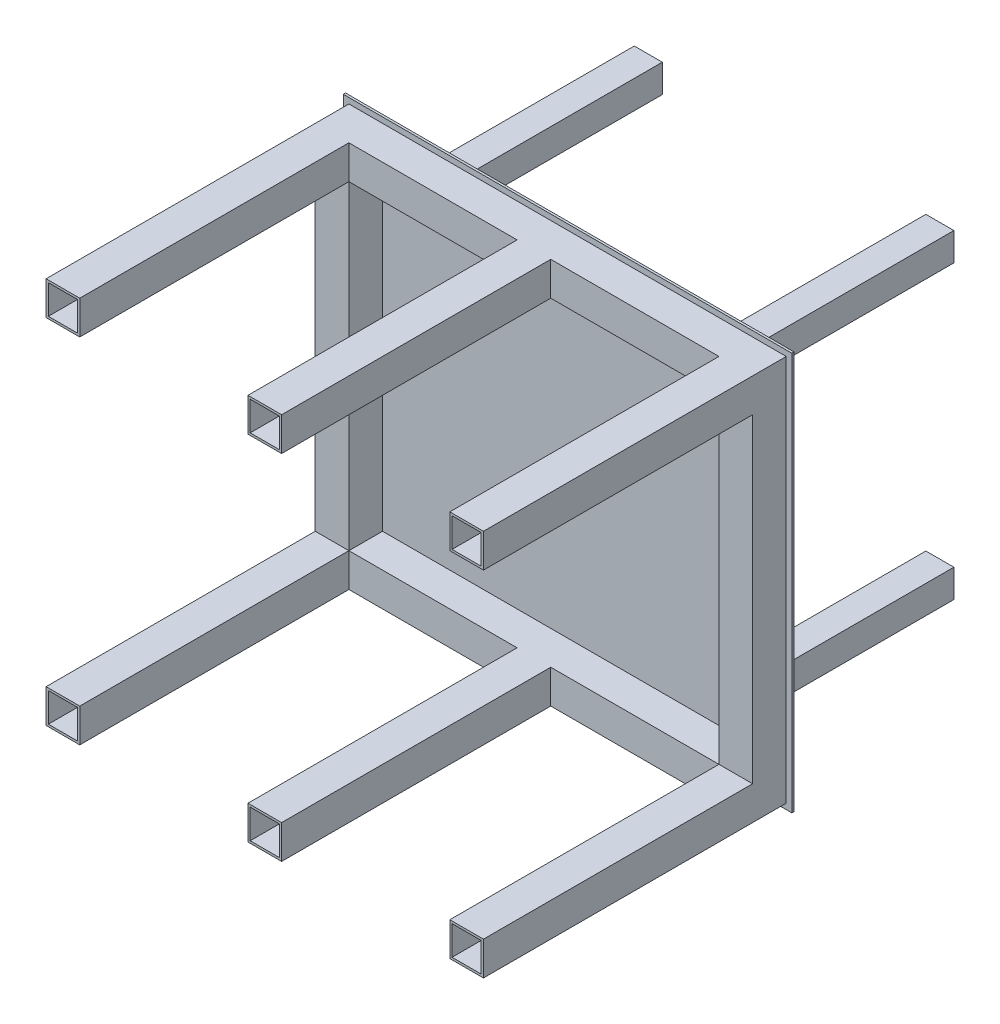
from build123d import *

# Parameters (mm, degrees)
SKETCH_1_W        = 30
SKETCH_1_H        = 30
SKETCH_1_W_2      = 26
SKETCH_1_H_2      = 26
EXTRUDE_1_DEPTH   = 270
EXTRUDE_1_2_DEPTH = 270
EXTRUDE_1_3_DEPTH = 270
EXTRUDE_1_4_DEPTH = 270
EXTRUDE_1_5_DEPTH = 270
EXTRUDE_1_6_DEPTH = 270
SKETCH_1_4_W      = 400
SKETCH_1_4_H      = 355
EXTRUDE_2_DEPTH   = 2
SKETCH_3_W        = 25
SKETCH_3_H        = 25
SKETCH_3_W_2      = 22
SKETCH_3_H_2      = 22
EXTRUDE_3_DEPTH   = 200
SKETCH_9_W        = 30
SKETCH_9_H        = 30
EXTRUDE_4_DEPTH   = 290
SKETCH_10_W       = 30
SKETCH_10_H       = 30
EXTRUDE_5_DEPTH   = 330


with BuildPart() as part:
    # 草圖1 → 填料-伸長1 (new body)
    with BuildSketch(Plane.XY):
        with Locations((-139.865693992, 17.660065035)):
            Rectangle(SKETCH_1_W, SKETCH_1_H)
        with Locations((-139.865693992, 17.660065035)):
            Rectangle(SKETCH_1_W_2, SKETCH_1_H_2, mode=Mode.SUBTRACT)
    extrude(amount=EXTRUDE_1_DEPTH)



with BuildPart() as body_2:
    # 草圖1 → Extrude 1 2 (new body)
    with BuildSketch(Plane.XY):
        with Locations((40.134306008, 17.660065035)):
            Rectangle(SKETCH_1_W, SKETCH_1_H)
        with Locations((40.134306008, 17.660065035)):
            Rectangle(SKETCH_1_W_2, SKETCH_1_H_2, mode=Mode.SUBTRACT)
    extrude(amount=EXTRUDE_1_2_DEPTH)


with BuildPart() as body_3:
    # 草圖1 → Extrude 1 3 (new body)
    with BuildSketch(Plane.XY):
        with Locations((220.134306008, 17.660065035)):
            Rectangle(SKETCH_1_W, SKETCH_1_H)
        with Locations((220.134306008, 17.660065035)):
            Rectangle(SKETCH_1_W_2, SKETCH_1_H_2, mode=Mode.SUBTRACT)
    extrude(amount=EXTRUDE_1_3_DEPTH)


with BuildPart() as body_4:
    # 草圖1 → Extrude 1 4 (new body)
    with BuildSketch(Plane.XY):
        with Locations((-139.865693992, -297.339934965)):
            Rectangle(SKETCH_1_W, SKETCH_1_H)
        with Locations((-139.865693992, -297.339934965)):
            Rectangle(SKETCH_1_W_2, SKETCH_1_H_2, mode=Mode.SUBTRACT)
    extrude(amount=EXTRUDE_1_4_DEPTH)


with BuildPart() as body_5:
    # 草圖1 → Extrude 1 5 (new body)
    with BuildSketch(Plane.XY):
        with Locations((40.134306008, -297.339934965)):
            Rectangle(SKETCH_1_W, SKETCH_1_H)
        with Locations((40.134306008, -297.339934965)):
            Rectangle(SKETCH_1_W_2, SKETCH_1_H_2, mode=Mode.SUBTRACT)
    extrude(amount=EXTRUDE_1_5_DEPTH)


with BuildPart() as body_6:
    # 草圖1 → Extrude 1 6 (new body)
    with BuildSketch(Plane.XY):
        with Locations((220.134306008, -297.339934965)):
            Rectangle(SKETCH_1_W, SKETCH_1_H)
        with Locations((220.134306008, -297.339934965)):
            Rectangle(SKETCH_1_W_2, SKETCH_1_H_2, mode=Mode.SUBTRACT)
    extrude(amount=EXTRUDE_1_6_DEPTH)


with BuildPart() as part_1:
    add(part.part)

    add(body_2.part)  # 填料-伸長2 merges body 2

    add(body_3.part)  # 填料-伸長2 merges body 3

    add(body_4.part)  # 填料-伸長2 merges body 4

    add(body_5.part)  # 填料-伸長2 merges body 5

    add(body_6.part)  # 填料-伸長2 merges body 6
    # 草圖1<4> → 填料-伸長2 (add)
    with BuildSketch(Plane.XY):
        with Locations((40.134306008, -139.839934965)):
            Rectangle(SKETCH_1_4_W, SKETCH_1_4_H)
    extrude(amount=-EXTRUDE_2_DEPTH)

    # 草圖3 → 填料-伸長3 (add)
    # profile 1 of 4: a face of its own
    with BuildSketch(Plane(origin=(0, 0, -2), x_dir=(-1, 0, 0), z_dir=(0, 0, -1))):
        with Locations((-170.134306008, -9.839934965)):
            Rectangle(SKETCH_3_W, SKETCH_3_H)
        with Locations((-170.134306008, -9.839934965)):
            Rectangle(SKETCH_3_W_2, SKETCH_3_H_2, mode=Mode.SUBTRACT)
    # profile 2 of 4: a face of its own
    with BuildSketch(Plane(origin=(0, 0, -2), x_dir=(-1, 0, 0), z_dir=(0, 0, -1))):
        with Locations((-170.134306008, -269.839934965)):
            Rectangle(SKETCH_3_W, SKETCH_3_H)
        with Locations((-170.134306008, -269.839934965)):
            Rectangle(SKETCH_3_W_2, SKETCH_3_H_2, mode=Mode.SUBTRACT)
    # profile 3 of 4: a face of its own
    with BuildSketch(Plane(origin=(0, 0, -2), x_dir=(-1, 0, 0), z_dir=(0, 0, -1))):
        with Locations((89.865693992, -269.839934965)):
            Rectangle(SKETCH_3_W, SKETCH_3_H)
        with Locations((89.865693992, -269.839934965)):
            Rectangle(SKETCH_3_W_2, SKETCH_3_H_2, mode=Mode.SUBTRACT)
    # profile 4 of 4: a face of its own
    with BuildSketch(Plane(origin=(0, 0, -2), x_dir=(-1, 0, 0), z_dir=(0, 0, -1))):
        with Locations((89.865693992, -9.839934965)):
            Rectangle(SKETCH_3_W, SKETCH_3_H)
        with Locations((89.865693992, -9.839934965)):
            Rectangle(SKETCH_3_W_2, SKETCH_3_H_2, mode=Mode.SUBTRACT)
    extrude(amount=EXTRUDE_3_DEPTH)

    # 草圖9 → 填料-伸長4 (add)
    with BuildSketch(Plane(origin=(0, -282.339934965, 0), x_dir=(1, 0, 0), z_dir=(0, 1, 0))):
        with Locations((220.134306008, -15)):
            Rectangle(SKETCH_9_W, SKETCH_9_H)
    extrude_4 = extrude(amount=EXTRUDE_4_DEPTH)

    # 鏡射1: 填料-伸長4 across plane
    add(extrude_4.mirror(Plane.ZY.offset(-40.134306008)))

    # 草圖10 → 填料-伸長5 (add)
    with BuildSketch(Plane.ZY.offset(-205.134306008)):
        with Locations((15, -297.339934965)):
            Rectangle(SKETCH_10_W, SKETCH_10_H)
        with Locations((15, 17.660065035)):
            Rectangle(SKETCH_10_W, SKETCH_10_H)
    extrude(amount=EXTRUDE_5_DEPTH)


solid = part_1.part
